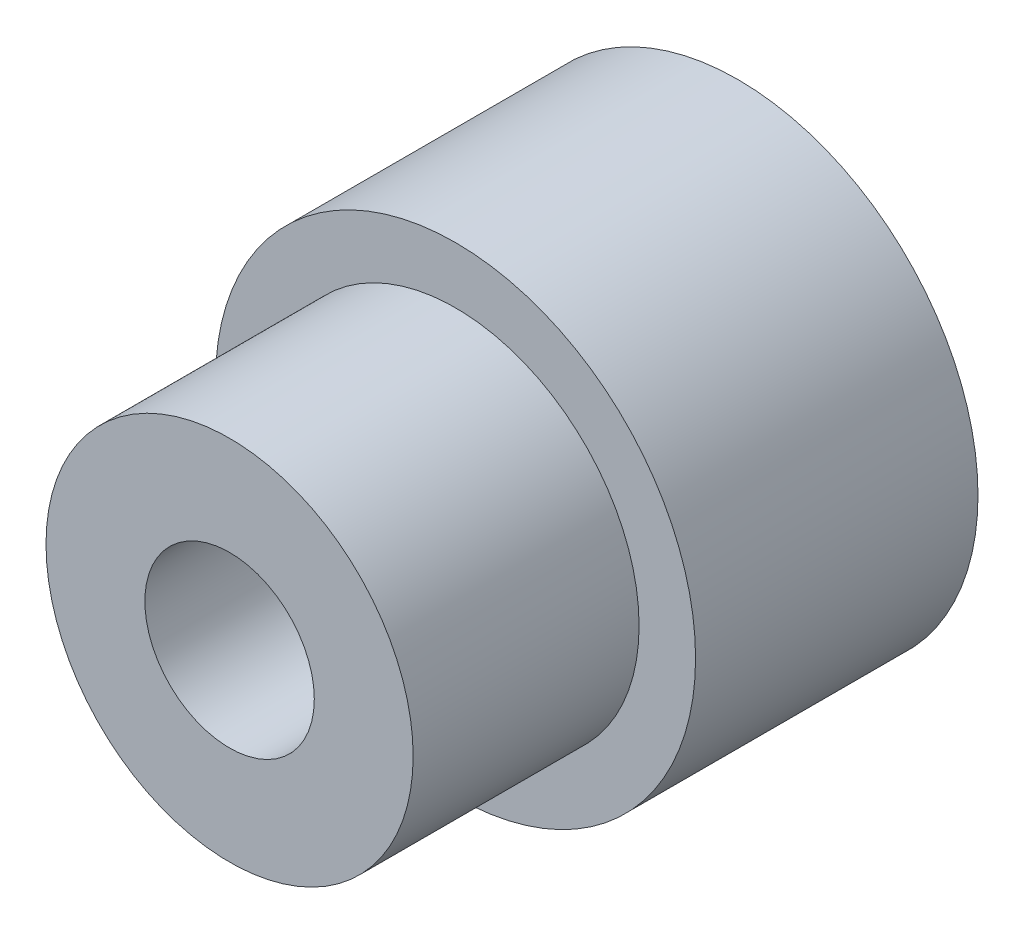
from build123d import *

# Parameters (mm, degrees)
SKETCH_1_R          = 8.5
EXTRUDE_1_DEPTH     = 10
SKETCH_2_R          = 6.5
EXTRUDE_2_DEPTH     = 8
SKETCH_3_R          = 3
CUT_EXTRUDE_1_DEPTH = 19


with BuildPart() as part:
    # 草图1 → 凸台-拉伸1 (new body)
    with BuildSketch(Plane.XY):
        Circle(SKETCH_1_R)
    extrude(amount=EXTRUDE_1_DEPTH)

    # 草图2 → 凸台-拉伸2 (add)
    with BuildSketch(Plane.XY.offset(10)):
        Circle(SKETCH_2_R)
    extrude(amount=EXTRUDE_2_DEPTH)

    # 草图3 → 切除-拉伸1 (cut, through all)
    with BuildSketch(Plane.XY.offset(18)):
        Circle(SKETCH_3_R)
    extrude(amount=-CUT_EXTRUDE_1_DEPTH, mode=Mode.SUBTRACT)


solid = part.part
